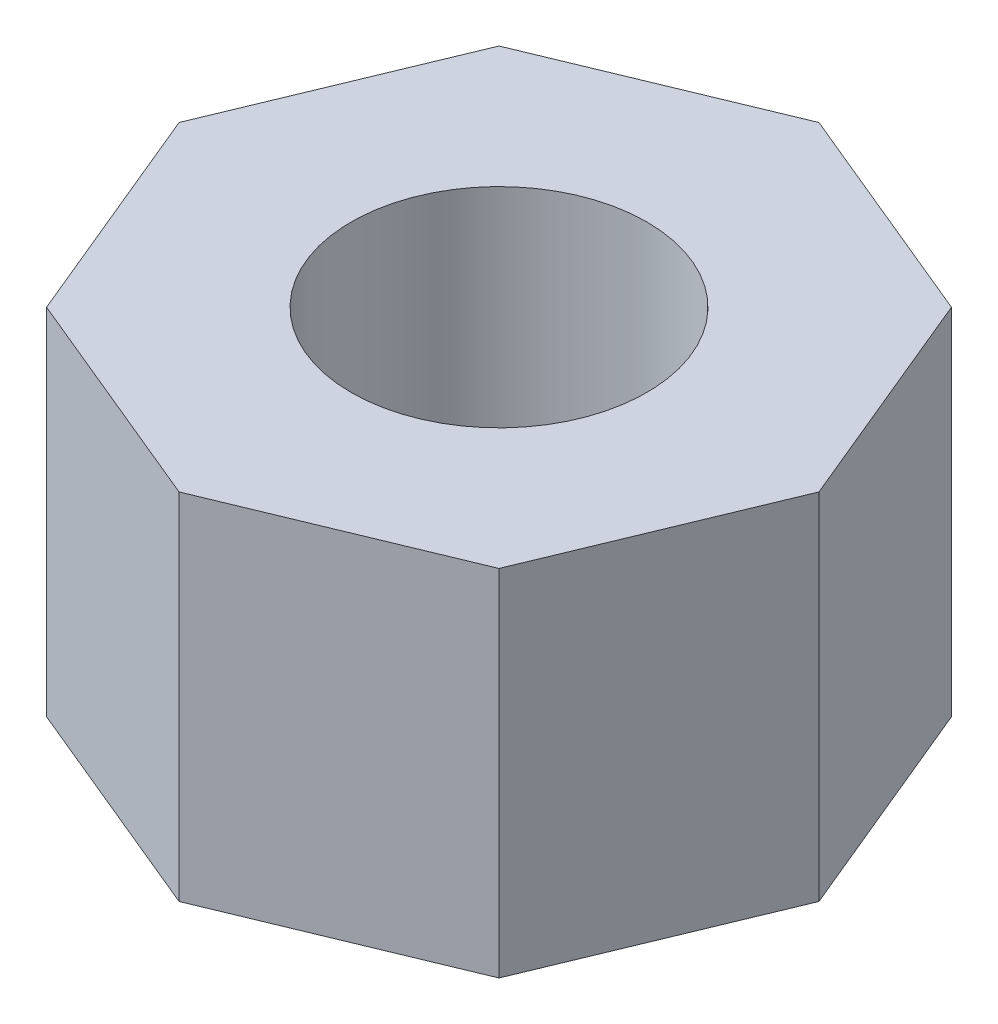
from build123d import *

# Parameters (mm, degrees)
SKETCH1_R           = 2.5
BOSS_EXTRUDE1_DEPTH = 6


with BuildPart() as part:
    # Sketch1 → Boss-Extrude1 (new body)
    with BuildSketch(Plane(origin=(0, 0, 0), x_dir=(1, 0, 0), z_dir=(0, 1, 0))):
        Polygon((0, -5.411961001), (3.826834324, -3.826834324), (5.411961001, 0), (3.826834324, 3.826834324), (0, 5.411961001), (-3.826834324, 3.826834324), (-5.411961001, 0), (-3.826834324, -3.826834324), align=None)
        Circle(SKETCH1_R, mode=Mode.SUBTRACT)
    extrude(amount=BOSS_EXTRUDE1_DEPTH)


solid = part.part
